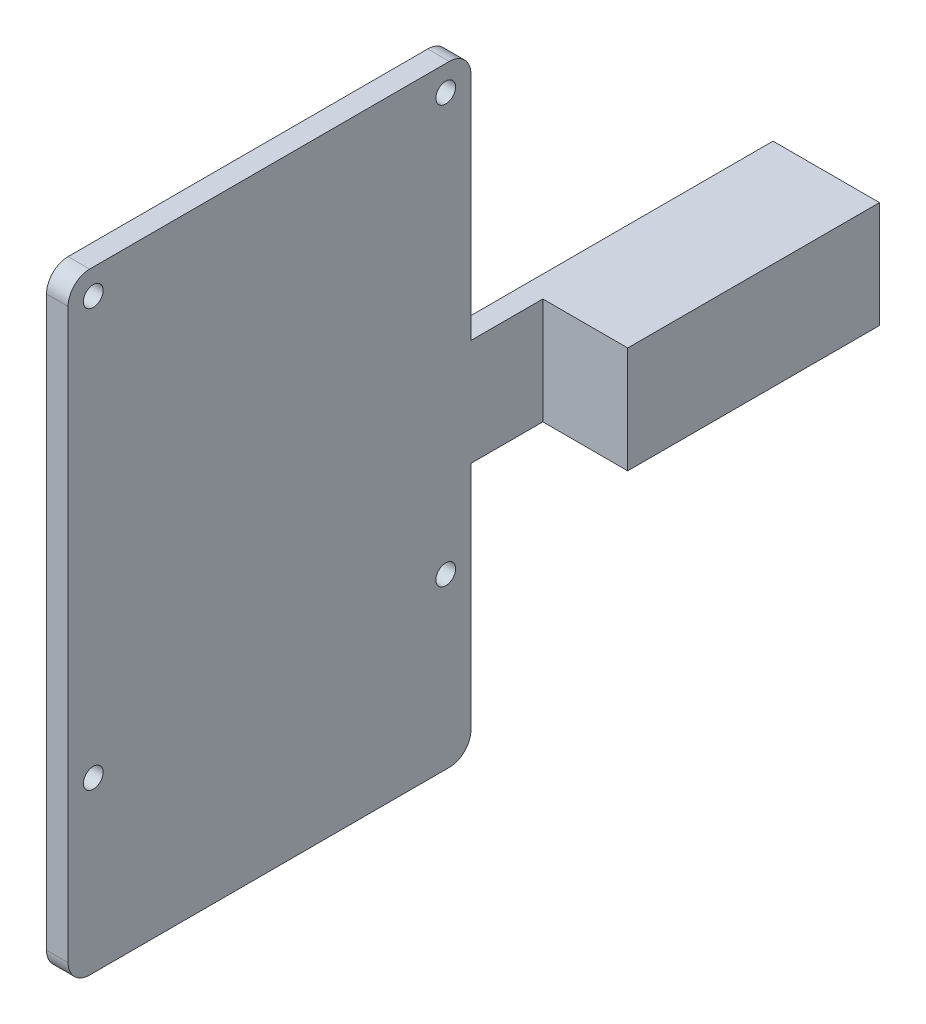
from build123d import *

# Parameters (mm, degrees)
SKETCH1_W           = 14.8
SKETCH1_H           = 14.8
BOSS_EXTRUDE1_DEPTH = 35
SKETCH3_W           = 3
SKETCH3_H           = 14.8
BOSS_EXTRUDE3_DEPTH = 10
SKETCH5_W           = 3
SKETCH5_H           = 85
BOSS_EXTRUDE4_DEPTH = 56
SKETCH6_R           = 1.375
CUT_EXTRUDE1_DEPTH  = 5
FILLET2_R           = 3


with BuildPart() as part:
    # Sketch1 → Boss-Extrude1 (new body)
    with BuildSketch(Plane.XY):
        Rectangle(SKETCH1_W, SKETCH1_H)
    extrude(amount=BOSS_EXTRUDE1_DEPTH)

    # Sketch3 → Boss-Extrude3 (add)
    with BuildSketch(Plane.XY.offset(35)):
        with Locations((-5.9, 0)):
            Rectangle(SKETCH3_W, SKETCH3_H)
    extrude(amount=BOSS_EXTRUDE3_DEPTH)

    # Sketch5 → Boss-Extrude4 (add)
    with BuildSketch(Plane.XY.offset(45)):
        with Locations((-5.9, 0)):
            Rectangle(SKETCH5_W, SKETCH5_H)
    extrude(amount=BOSS_EXTRUDE4_DEPTH)

    # Sketch6 → Cut-Extrude1 (cut)
    with BuildSketch(Plane(origin=(-4.4, 0, 0), x_dir=(0, 0, -1), z_dir=(1, 0, 0))):
        with Locations((-97.5, 39)):
            Circle(SKETCH6_R)
        with Locations((-48.5, 39)):
            Circle(SKETCH6_R)
        with Locations((-48.5, -19)):
            Circle(SKETCH6_R)
        with Locations((-97.5, -19)):
            Circle(SKETCH6_R)
    extrude(amount=-CUT_EXTRUDE1_DEPTH, mode=Mode.SUBTRACT)

    # Fillet2
    fillet2_edges = [part.edges().sort_by_distance(p)[0] for p in [
        (-5.9, -42.5, 45),
        (-5.9, 42.5, 45),
        (-5.9, -42.5, 101),
        (-5.9, 42.5, 101),
    ]]
    fillet(fillet2_edges, radius=FILLET2_R)


solid = part.part
